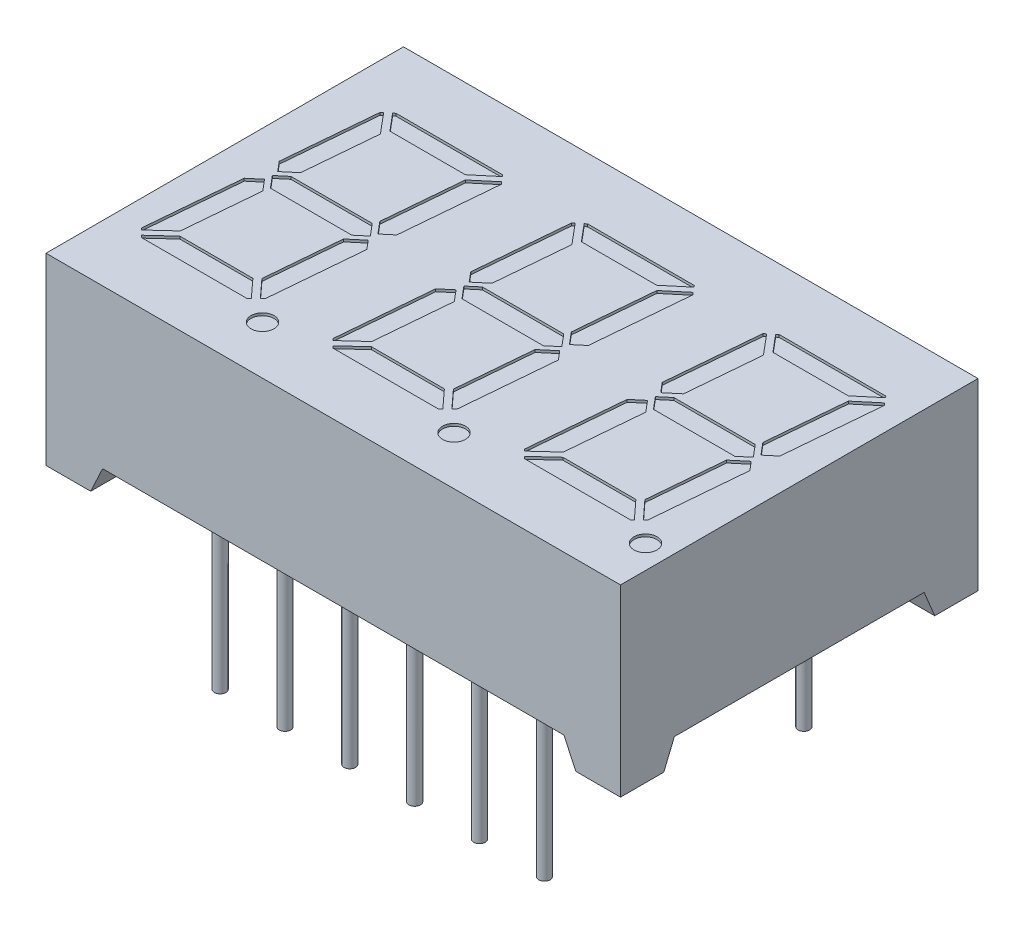
from build123d import *

# Parameters (mm, degrees)
SKETCH1_W                       = 22.5
SKETCH1_H                       = 14
EXTRUDE1_DEPTH                  = 7.2
SKETCH6_R                       = 0.45
CUT_EXTRUDE1_DEPTH              = 0.1
CUT_EXTRUDE2_DEPTH              = 25.639196415
CUT_EXTRUDE2_DEPTH_BACK         = 25.639196415
CUT_EXTRUDE3_DEPTH              = 20.349483197
CUT_EXTRUDE3_DEPTH_BACK         = 20.349483197
LPATTERN1_COUNT                 = 2
LPATTERN1_PITCH                 = 7.5
LPATTERN2_COUNT                 = 2
LPATTERN2_PITCH                 = 7.5
SKETCH11_R                      = 0.225
BOSS_EXTRUDE4_DEPTH             = 6.1
BOSS_EXTRUDE4_DIRECTION_2_REACH = 17.08
LPATTERN3_COUNT                 = 6
LPATTERN3_PITCH                 = 2.54
LPATTERN3_COUNT_DIR2            = 2
LPATTERN3_PITCH_DIR2            = 10.16


with BuildPart() as part:
    # Sketch1 → Extrude1 (new body)
    with BuildSketch(Plane(origin=(0, 0, 0), x_dir=(1, 0, 0), z_dir=(0, 1, 0))):
        Rectangle(SKETCH1_W, SKETCH1_H)
    extrude(amount=-EXTRUDE1_DEPTH)

    # Sketch6 → Cut-Extrude1 (cut)
    with BuildSketch(Plane(origin=(0, 0, 0), x_dir=(-1, 0, 0), z_dir=(0, 1, 0))):
        with Locations((-2.828914589, 5.1)):
            Circle(SKETCH6_R)
        Polygon((1.615140342, 0.645647316), (1.874984591, 3.615680666), (2.672057265, 4.346063205), (2.736318521, 4.281801948), (2.412096101, 0.575922722), (1.978755924, 0.212307139), align=None)
        Polygon((-2.08510989, 4.246446609), (-2.404999919, 0.590086851), (-2.118563171, 0.248724827), (-1.593244842, 0.689519243), (-1.335889658, 3.631102448), (-1.988382771, 4.343173729), align=None)
        Polygon((-2.751982586, -4.346963991), (-2.828914589, -4.255280001), (-2.499336567, -0.488185972), (-2.097293847, -0.150832074), (-1.707416581, -0.615469707), (-1.976986224, -3.696664829), align=None)
        Polygon((-2.591285684, -4.538475102), (-1.79792785, -3.872768836), (1.154576659, -3.872768836), (1.713170541, -4.538475102), (1.639848023, -4.6), (-2.539660165, -4.6), align=None)
        Polygon((1.560181456, -0.4), (1.954104558, -0.069459271), (1.560181456, 0.4), (-1.627135675, 0.4), (-2.021058776, 0.069459271), (-1.627135675, -0.4), align=None)
        Polygon((2.495112157, 4.523008313), (2.41812047, 4.6), (-1.7315565, 4.6), (-1.811437663, 4.520118836), (-1.151570324, 3.8), (1.706087039, 3.8), align=None)
        Polygon((1.982853172, -0.306417777), (2.30166085, -0.686357973), (1.984568022, -4.310745576), (1.904681652, -4.377778199), (1.244483112, -3.590984217), (1.496113015, -0.714841264), align=None)
    cut_extrude1 = extrude(amount=-CUT_EXTRUDE1_DEPTH, mode=Mode.SUBTRACT)

    # Sketch12 → Cut-Extrude2 (cut, two sides: drawn at the far end of the back side and taken through both)
    with BuildSketch(Plane.ZY.offset(11.25).offset(-CUT_EXTRUDE2_DEPTH_BACK)):
        Polygon((-20.043427491, -42.781711537), (-5.305, -7.2), (-4.890786438, -6.2), (4.890786438, -6.2), (5.305, -7.2), (20.043427491, -42.781711537), (20.043427491, -119.808445619), (-20.043427491, -119.808445619), align=None)
    extrude(amount=CUT_EXTRUDE2_DEPTH + CUT_EXTRUDE2_DEPTH_BACK, mode=Mode.SUBTRACT)

    # Sketch13 → Cut-Extrude3 (cut, two sides: drawn at the far end of the back side and taken through both)
    with BuildSketch(Plane(origin=(0, 0, -7), x_dir=(-1, 0, 0), z_dir=(0, 0, -1)).offset(-CUT_EXTRUDE3_DEPTH_BACK)):
        Polygon((-32.290672921, -56.074755802), (-9.5, -7.2), (-9.033692342, -6.2), (9.033692342, -6.2), (9.5, -7.2), (32.290672921, -56.074755802), (32.290672921, -163.929408496), (-32.290672921, -163.929408496), align=None)
    extrude(amount=CUT_EXTRUDE3_DEPTH + CUT_EXTRUDE3_DEPTH_BACK, mode=Mode.SUBTRACT)

    # LPattern1: Cut-Extrude1 ×2
    with Locations(*[(i * LPATTERN1_PITCH, 0, 0) for i in range(1, LPATTERN1_COUNT)]):
        add(cut_extrude1, mode=Mode.SUBTRACT)

    # LPattern2: Cut-Extrude1 ×2
    with Locations(*[(-i * LPATTERN2_PITCH, 0, 0) for i in range(1, LPATTERN2_COUNT)]):
        add(cut_extrude1, mode=Mode.SUBTRACT)

    # Sketch11 → Boss-Extrude4 (add)
    with BuildSketch(Plane.XZ.offset(7.2)):
        with Locations((6.35, 5.08)):
            Circle(SKETCH11_R)
    boss_extrude4 = extrude(amount=BOSS_EXTRUDE4_DEPTH)

    # Sketch11 → Boss-Extrude4 direction 2 (add, up to next)
    with BuildSketch(Plane.XZ.offset(7.2), mode=Mode.PRIVATE) as boss_extrude4_direction_2_sk1:
        with Locations((6.35, 5.08)):
            Circle(SKETCH11_R)
    boss_extrude4_direction_2_tool1 = extrude(boss_extrude4_direction_2_sk1.sketch, amount=-BOSS_EXTRUDE4_DIRECTION_2_REACH, mode=Mode.PRIVATE) - part.part
    boss_extrude4_direction_2 = boss_extrude4_direction_2_tool1.solids().sort_by_distance((6.35, -7.2, 5.08))[0]
    add(boss_extrude4_direction_2)

    # LPattern3: Boss-Extrude4, Boss-Extrude4 direction 2 6 × 2
    with Locations(*[(-i * LPATTERN3_PITCH, 0, -j * LPATTERN3_PITCH_DIR2) for i in range(LPATTERN3_COUNT) for j in range(LPATTERN3_COUNT_DIR2) if (i, j) != (0, 0)]):
        add(boss_extrude4)
        add(boss_extrude4_direction_2)


solid = part.part
